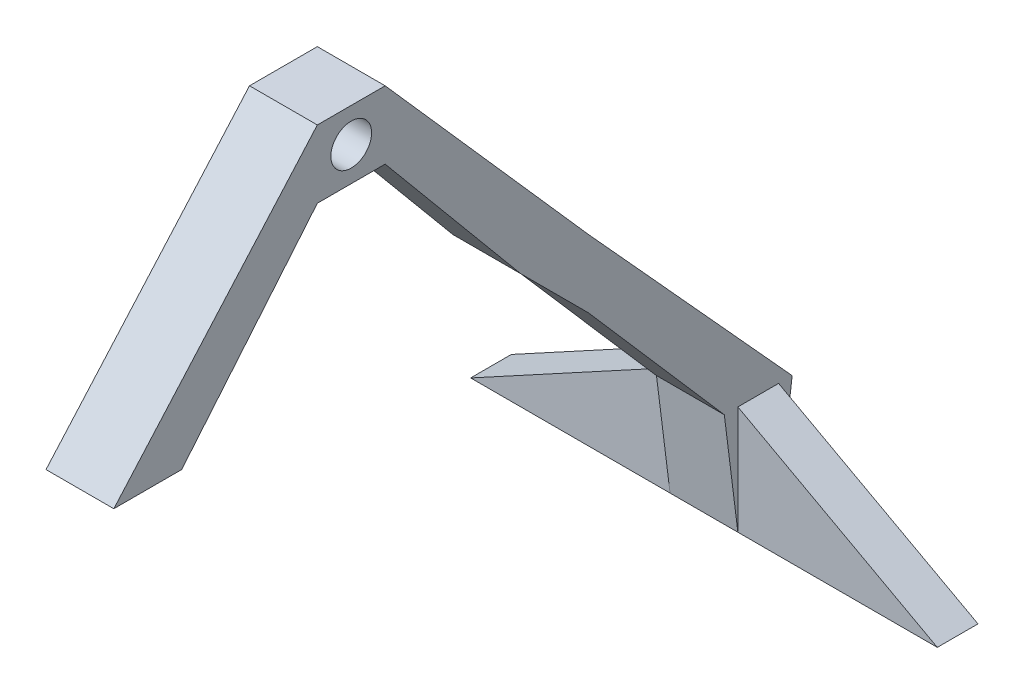
from build123d import *

# Parameters (mm, degrees)
SKETCH2_W                  = 25
SKETCH2_H                  = 5
SKETCH2_H_2                = 15
SKETCH2_W_2                = 73.5
BOSS_EXTRUDE3_DEPTH        = 40
CUT_EXTRUDE1_DEPTH         = 15
CUT_EXTRUDE3_DEPTH         = 25
SKETCH5_W                  = 25
SKETCH5_H                  = 25
BOSS_EXTRUDE4_DEPTH        = 12.5
BOSS_EXTRUDE4_DEPTH_BACK   = 12.5
BOSS_EXTRUDE4_2_DEPTH      = 12.5
BOSS_EXTRUDE4_2_DEPTH_BACK = 12.5
BOSS_EXTRUDE5_START        = -12.5
BOSS_EXTRUDE5_DEPTH        = 25
SKETCH9_W                  = 25
SKETCH9_H                  = 25
SKETCH9_R                  = 7.5
BOSS_EXTRUDE6_DEPTH        = 12.5
BOSS_EXTRUDE6_DEPTH_BACK   = 12.5
BOSS_EXTRUDE7_DEPTH        = 12.5
BOSS_EXTRUDE7_DEPTH_BACK   = 12.5
BOSS_EXTRUDE8_DEPTH        = 12.5
BOSS_EXTRUDE8_DEPTH_BACK   = 12.5
CUT_EXTRUDE4_REACH         = 100.5
SKETCH12_W                 = 25
SKETCH12_H                 = 25
CUT_EXTRUDE5_REACH         = 100.5


with BuildPart() as part:
    # Sketch2 → Boss-Extrude3 (new body)
    with BuildSketch(Plane(origin=(0, 0, 0), x_dir=(1, 0, 0), z_dir=(0, 1, 0))):
        with Locations((0, -10)):
            Rectangle(SKETCH2_W, SKETCH2_H)
        Rectangle(SKETCH2_W, SKETCH2_H_2)
        with Locations((0, 10)):
            Rectangle(SKETCH2_W, SKETCH2_H)
        with Locations((-49.25, 0)):
            Rectangle(SKETCH2_W_2, SKETCH2_H_2)
        with Locations((49.25, 0)):
            Rectangle(SKETCH2_W_2, SKETCH2_H_2)
    extrude(amount=BOSS_EXTRUDE3_DEPTH)

    # Sketch6 → Cut-Extrude1 (cut)
    with BuildSketch(Plane(origin=(0, 0, -7.5), x_dir=(-1, 0, 0), z_dir=(0, 0, -1))):
        Polygon((12.5, 40), (86, 0), (86, 40), align=None)
    cut_extrude1 = extrude(amount=-CUT_EXTRUDE1_DEPTH, mode=Mode.SUBTRACT)

    # Mirror1: Cut-Extrude1 across plane
    add(cut_extrude1.mirror(Plane(origin=(0, 0, 0), x_dir=(0, 0, 1), z_dir=(1, 0, 0))), mode=Mode.SUBTRACT)

    # Sketch7 → Cut-Extrude3 (cut)
    with BuildSketch(Plane.ZY.offset(12.5)):
        Polygon((-12.5, 40), (-7.5, 0), (-12.5, 0), align=None)
    cut_extrude3 = extrude(amount=-CUT_EXTRUDE3_DEPTH, mode=Mode.SUBTRACT)

    # Mirror2: Cut-Extrude3 across plane
    add(cut_extrude3.mirror(Plane.XY), mode=Mode.SUBTRACT)



with BuildPart() as body_2:
    # Sketch5 → Boss-Extrude4 (new body, two sides)
    with BuildSketch(Plane(origin=(0, 0, 0), x_dir=(0, 0, -1), z_dir=(1, 0, 0))) as boss_extrude4_sk:
        with Locations((-75, 110)):
            Rectangle(SKETCH5_W, SKETCH5_H)
    extrude(amount=BOSS_EXTRUDE4_DEPTH)
    extrude(boss_extrude4_sk.sketch, amount=-BOSS_EXTRUDE4_DEPTH_BACK)


with BuildPart() as body_3:
    # Sketch5 → Boss-Extrude4 2 (new body, two sides)
    with BuildSketch(Plane(origin=(0, 0, 0), x_dir=(0, 0, -1), z_dir=(1, 0, 0))) as boss_extrude4_2_sk:
        with Locations((-225, 110)):
            Rectangle(SKETCH5_W, SKETCH5_H)
    extrude(amount=BOSS_EXTRUDE4_2_DEPTH)
    extrude(boss_extrude4_2_sk.sketch, amount=-BOSS_EXTRUDE4_2_DEPTH_BACK)


with BuildPart() as part_1:
    add(part.part)

    add(body_2.part)  # Boss-Extrude5 merges body 2
    # Sketch8 → Boss-Extrude5 (add)
    with BuildSketch(Plane(origin=(0, 0, 0), x_dir=(0, 0, -1), z_dir=(1, 0, 0)).offset(BOSS_EXTRUDE5_START)):
        Polygon((-62.5, 97.5), (-12.5, 40), (12.5, 40), (-62.5, 122.5), align=None)
    extrude(amount=BOSS_EXTRUDE5_DEPTH)



with BuildPart() as body_3_2:
    # Sketch9 → Boss-Extrude6 (new body, two sides)
    with BuildSketch(Plane(origin=(0, 0, 0), x_dir=(0, 0, -1), z_dir=(1, 0, 0))) as boss_extrude6_sk:
        with Locations((-150, 195)):
            Rectangle(SKETCH9_W, SKETCH9_H)
        with Locations((-150, 195)):
            Circle(SKETCH9_R, mode=Mode.SUBTRACT)
    extrude(amount=BOSS_EXTRUDE6_DEPTH)
    extrude(boss_extrude6_sk.sketch, amount=-BOSS_EXTRUDE6_DEPTH_BACK)


with BuildPart() as part_2:
    add(part_1.part)

    add(body_3_2.part)  # Boss-Extrude7 merges body 3 2
    # Sketch10 → Boss-Extrude7 (add, two sides)
    with BuildSketch(Plane(origin=(0, 0, 0), x_dir=(0, 0, -1), z_dir=(1, 0, 0))) as boss_extrude7_sk:
        Polygon((-137.5, 182.5), (-87.5, 122.5), (-62.5, 122.5), (-137.5, 207.5), align=None)
    extrude(amount=BOSS_EXTRUDE7_DEPTH)
    extrude(boss_extrude7_sk.sketch, amount=-BOSS_EXTRUDE7_DEPTH_BACK)


    add(body_3.part)  # Boss-Extrude8 merges body 3
    # Sketch11 → Boss-Extrude8 (add, two sides)
    with BuildSketch(Plane(origin=(0, 0, 0), x_dir=(0, 0, -1), z_dir=(1, 0, 0))) as boss_extrude8_sk:
        Polygon((-162.5, 182.5), (-212.5, 122.5), (-237.5, 122.5), (-162.5, 207.5), align=None)
    extrude(amount=BOSS_EXTRUDE8_DEPTH)
    extrude(boss_extrude8_sk.sketch, amount=-BOSS_EXTRUDE8_DEPTH_BACK)

    # Sketch12 → Cut-Extrude4 (cut, up to next)
    with BuildSketch(Plane.ZY.offset(12.5), mode=Mode.PRIVATE) as cut_extrude4_sk1:
        with Locations((225, 110)):
            Rectangle(SKETCH12_W, SKETCH12_H)
    cut_extrude4_tool1 = extrude(cut_extrude4_sk1.sketch, amount=-CUT_EXTRUDE4_REACH, mode=Mode.PRIVATE) & part_2.part
    add(cut_extrude4_tool1.solids().sort_by_distance((-12.5, 110, 225))[0], mode=Mode.SUBTRACT)

    # Sketch13 → Cut-Extrude5 (cut, up to next)
    with BuildSketch(Plane.ZY.offset(12.5), mode=Mode.PRIVATE) as cut_extrude5_sk1:
        Polygon((87.5, 122.5), (62.5, 97.5), (87.5, 97.5), align=None)
    cut_extrude5_tool1 = extrude(cut_extrude5_sk1.sketch, amount=-CUT_EXTRUDE5_REACH, mode=Mode.PRIVATE) & part_2.part
    add(cut_extrude5_tool1.solids().sort_by_distance((-12.5, 105.833333, 79.166667))[0], mode=Mode.SUBTRACT)


solid = part_2.part
